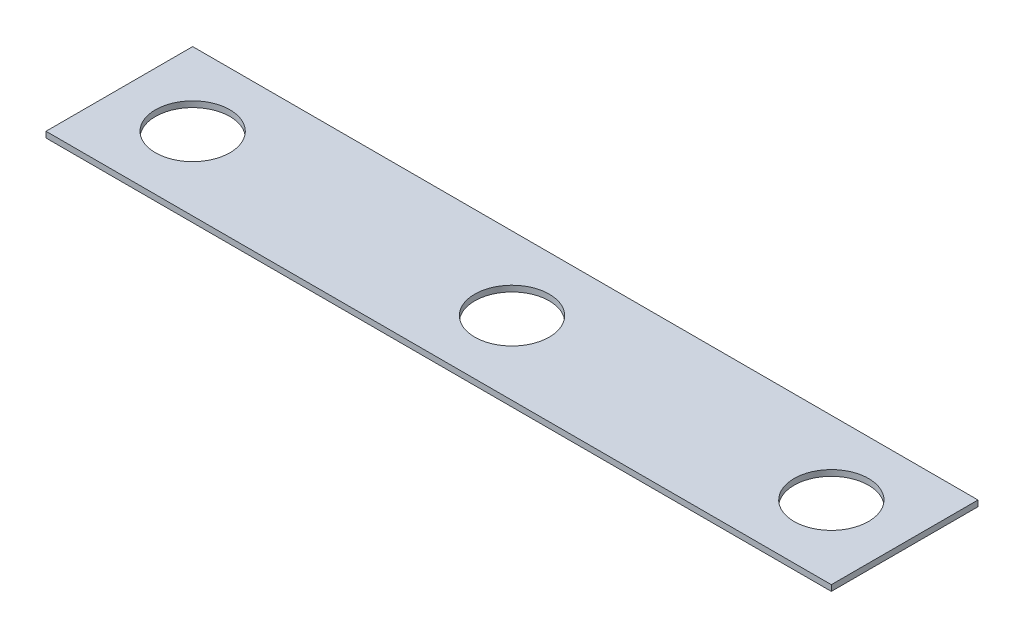
from build123d import *

# Parameters (mm, degrees)
SKETCH1_W                 = 17
SKETCH1_H                 = 3.175
BOSS_EXTRUDE1_DEPTH       = 0.127
F_0_CLEARANCE_HOLE1_D     = 1.6129
F_0_CLEARANCE_HOLE1_DEPTH = 4.826
F_0_CLEARANCE_HOLE1_TIP   = 0.484564046


with BuildPart() as part:
    # Sketch1 → Boss-Extrude1 (new body)
    with BuildSketch(Plane(origin=(0, 0, 0), x_dir=(1, 0, 0), z_dir=(0, 1, 0))):
        Rectangle(SKETCH1_W, SKETCH1_H)
    extrude(amount=BOSS_EXTRUDE1_DEPTH)

    # #0 Clearance Hole1
    with Locations(Plane(origin=(0, 0.127, 0), x_dir=(-1, 0, 0), z_dir=(0, 1, 0))):
        with Locations((0, 0), (-6.9125, 0), (6.9125, 0)):
            Hole(F_0_CLEARANCE_HOLE1_D / 2, depth=F_0_CLEARANCE_HOLE1_DEPTH)
            with Locations((0, 0, -(F_0_CLEARANCE_HOLE1_DEPTH + F_0_CLEARANCE_HOLE1_TIP / 2))):  # 118° drill point
                Cone(0, F_0_CLEARANCE_HOLE1_D / 2, F_0_CLEARANCE_HOLE1_TIP, mode=Mode.SUBTRACT)


solid = part.part
